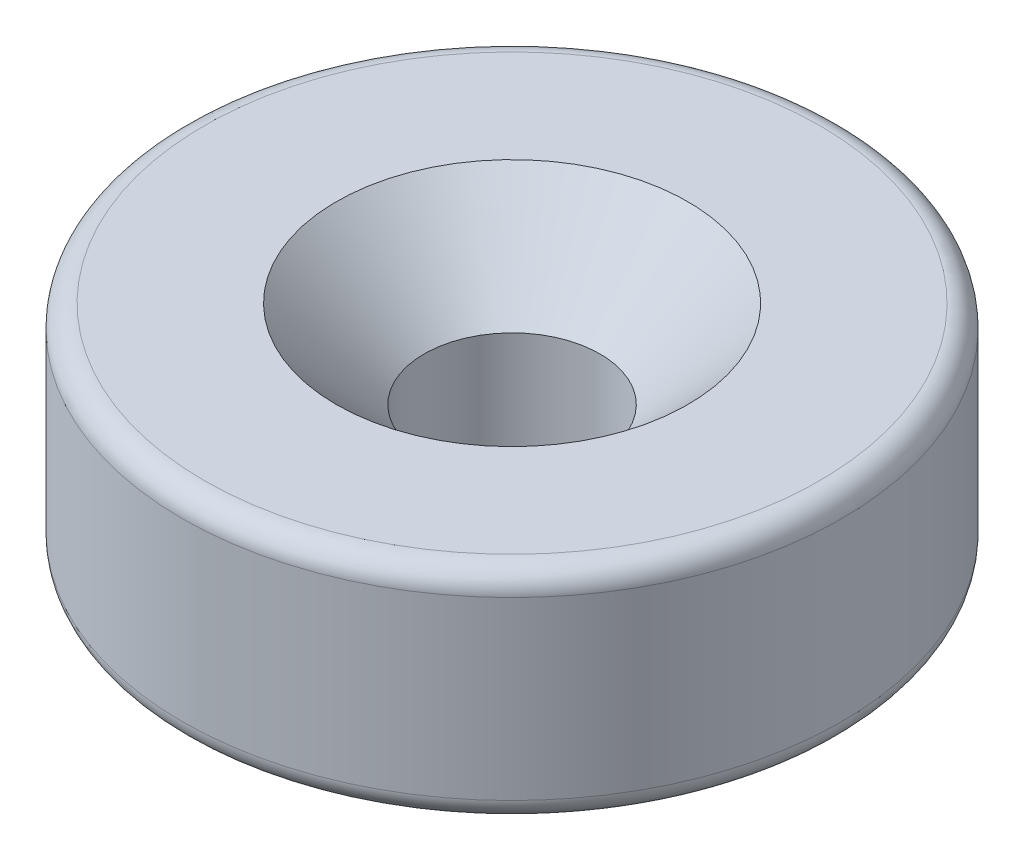
from build123d import *

# Parameters (mm, degrees)
SKETCH1_R           = 7.5
SKETCH1_R_2         = 2
BOSS_EXTRUDE1_DEPTH = 2.5
FILLET1_R           = 0.5
CHAMFER1_SIZE       = 2


with BuildPart() as part:
    # Sketch1 → Boss-Extrude1 (new body, symmetric)
    with BuildSketch(Plane(origin=(0, 0, 0), x_dir=(1, 0, 0), z_dir=(0, 1, 0))):
        Circle(SKETCH1_R)
        Circle(SKETCH1_R_2, mode=Mode.SUBTRACT)
    extrude(amount=BOSS_EXTRUDE1_DEPTH, both=True)

    # Fillet1
    fillet1_edges = [part.edges().sort_by_distance(p)[0] for p in [
        (-7.5, -2.5, 0),
        (-7.5, 2.5, 0),
    ]]
    fillet(fillet1_edges, radius=FILLET1_R)

    # Chamfer1
    chamfer1_edges = [part.edges().sort_by_distance(p)[0] for p in [
        (-2, 2.5, 0),
    ]]
    chamfer(chamfer1_edges, length=CHAMFER1_SIZE)


solid = part.part
